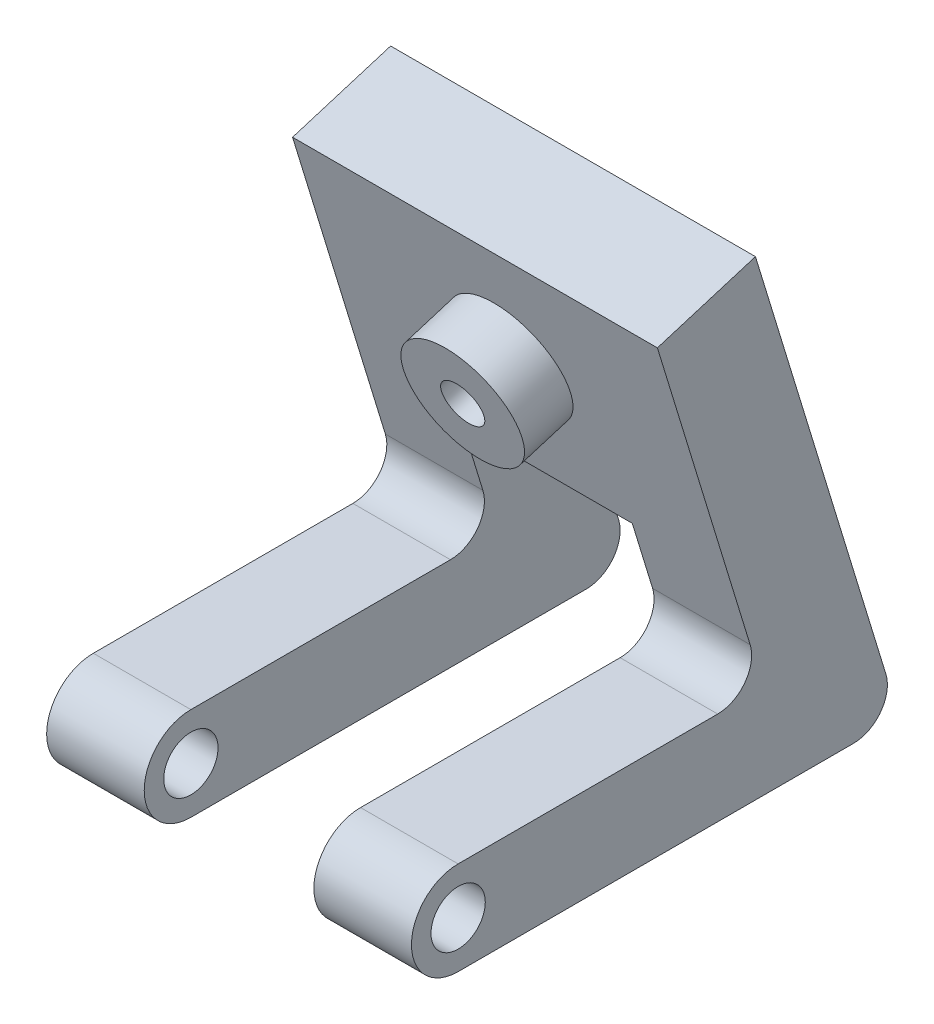
from build123d import *

# Parameters (mm, degrees)
SKETCH1_R               = 2.032
BOSS_EXTRUDE1_DEPTH     = 27.305
FILLET1_R               = 2.54
SKETCH2_W               = 12.7
SKETCH2_H               = 15.24
CUT_EXTRUDE1_DEPTH      = 4.4925
CUT_EXTRUDE1_DEPTH_BACK = 33.127387008
SKETCH3_R               = 4.445
SKETCH3_R_2             = 1.5875
BOSS_EXTRUDE2_DEPTH     = 3.796503


with BuildPart() as part:
    # Sketch1 → Boss-Extrude1 (new body)
    with BuildSketch(Plane(origin=(0, 0, 0), x_dir=(0, 0, -1), z_dir=(1, 0, 0))):
        with BuildLine():
            Line((0, 3.4925), (22.86, 3.4925))
            Line((22.86, 3.4925), (14.913420462, 29.48459049))
            Line((14.913420462, 29.48459049), (22.251950115, 31.728204162))
            Line((22.251950115, 31.728204162), (33.02, -3.4925))
            Line((33.02, -3.4925), (0, -3.4925))
            ThreePointArc((0, -3.4925), (-3.4925, 0), (0, 3.4925))
        make_face()
        Circle(SKETCH1_R, mode=Mode.SUBTRACT)
    extrude(amount=BOSS_EXTRUDE1_DEPTH)

    # Fillet1
    fillet1_edges = [part.edges().sort_by_distance(p)[0] for p in [
        (13.6525, 3.4925, -22.86),
        (13.6525, -3.4925, -33.02),
    ]]
    fillet(fillet1_edges, radius=FILLET1_R)

    # Sketch2 → Cut-Extrude1 (cut, two sides)
    with BuildSketch(Plane.XY) as cut_extrude1_sk:
        with Locations((13.6525, 4.1275)):
            Rectangle(SKETCH2_W, SKETCH2_H)
    extrude(amount=CUT_EXTRUDE1_DEPTH, mode=Mode.SUBTRACT)
    extrude(cut_extrude1_sk.sketch, amount=-CUT_EXTRUDE1_DEPTH_BACK, mode=Mode.SUBTRACT)

    # Sketch3 → Boss-Extrude2 (add)
    with BuildSketch(Plane(origin=(0, 6.690118026, -21.882390062), x_dir=(1, 0, 0), z_dir=(0, -0.292371705, 0.956304756))):
        with Locations((13.6525, 14.562227295)):
            Circle(SKETCH3_R)
        with Locations((13.6525, 14.562227295)):
            Circle(SKETCH3_R_2, mode=Mode.SUBTRACT)
    extrude(amount=BOSS_EXTRUDE2_DEPTH)


solid = part.part
